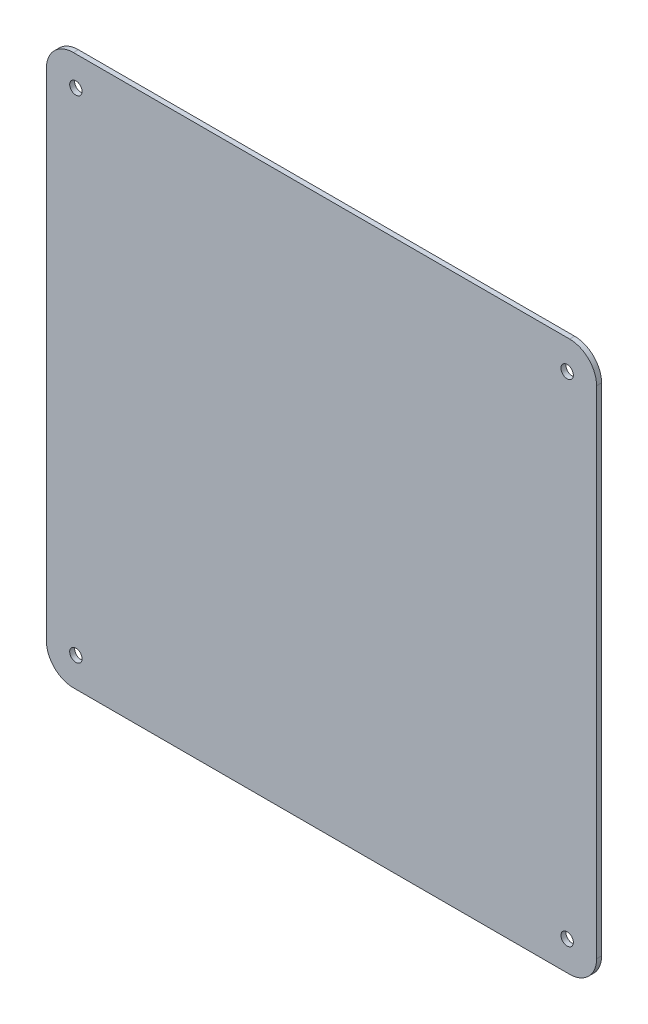
from build123d import *

# Parameters (mm, degrees)
BOSS_EXTRUDE1_DEPTH      = 1.6
F_4_0_4_DIAMETER_HOLE1_D = 4


with BuildPart() as part:
    # Sketch1 → Boss-Extrude1 (new body)
    with BuildSketch(Plane.XY):
        with BuildLine():
            Line((-80, 88.7), (80, 88.7))
            ThreePointArc((80, 88.7), (86.151828996, 86.151828996), (88.7, 80))
            Line((88.7, 80), (88.7, -80))
            ThreePointArc((88.7, -80), (86.151828996, -86.151828996), (80, -88.7))
            Line((80, -88.7), (-80, -88.7))
            ThreePointArc((-80, -88.7), (-86.151828996, -86.151828996), (-88.7, -80))
            Line((-88.7, -80), (-88.7, 80))
            ThreePointArc((-88.7, 80), (-86.151828996, 86.151828996), (-80, 88.7))
        make_face()
    extrude(amount=BOSS_EXTRUDE1_DEPTH)

    # Ø4.0 (4) Diameter Hole1 (through all)
    with Locations(Plane(origin=(0, 0, 0), x_dir=(-1, 0, 0), z_dir=(0, 0, -1))):
        with Locations((-79.2, 79.2), (79.2, 79.2), (-79.2, -79.2), (79.2, -79.2)):
            Hole(F_4_0_4_DIAMETER_HOLE1_D / 2)


solid = part.part
